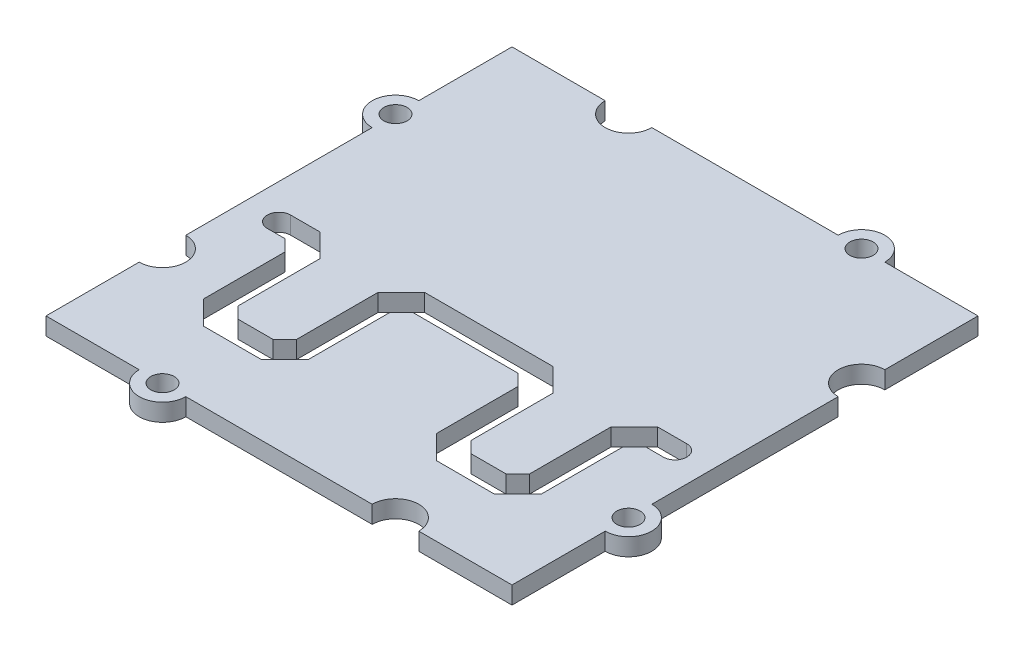
from build123d import *

# Parameters (mm, degrees)
ESQUISSE1_R        = 1
BOSS_EXTRU_1_DEPTH = 1.5


with BuildPart() as part:
    # Esquisse1 → Boss.-Extru.1 (new body)
    with BuildSketch(Plane(origin=(0, 0, 0), x_dir=(1, 0, 0), z_dir=(0, 1, 0))):
        with BuildLine():
            Line((-20, 20), (-12, 20))
            ThreePointArc((-12, 20), (-10, 18), (-8, 20))
            Line((-8, 20), (8, 20))
            ThreePointArc((8, 20), (10, 22), (12, 20))
            Line((12, 20), (20, 20))
            Line((20, 20), (20, 12.001401689))
            ThreePointArc((20, 12.001401689), (17.998598311, 10), (20, 7.998598311))
            Line((20, 7.998598311), (20, -8))
            ThreePointArc((20, -8), (22, -10), (20, -12))
            Line((20, -12), (20, -20))
            Line((20, -20), (12, -20))
            ThreePointArc((12, -20), (10, -18), (8, -20))
            Line((8, -20), (-8, -20))
            ThreePointArc((-8, -20), (-10, -22), (-12, -20))
            Line((-12, -20), (-20, -20))
            Line((-20, -20), (-20, -12))
            ThreePointArc((-20, -12), (-18, -10), (-20, -8))
            Line((-20, -8), (-20, 8))
            ThreePointArc((-20, 8), (-22, 10), (-20, 12))
            Line((-20, 12), (-20, 20))
        make_face()
        with Locations(Location((-10, -20, 0), (0, 0, 270))):  # turned: the seam where the file's is
            Circle(ESQUISSE1_R, mode=Mode.SUBTRACT)
        with Locations(Location((20, -10, 0), (0, 0, 270))):  # turned: the seam where the file's is
            Circle(ESQUISSE1_R, mode=Mode.SUBTRACT)
        with Locations(Location((-20, 10, 0), (0, 0, 270))):  # turned: the seam where the file's is
            Circle(ESQUISSE1_R, mode=Mode.SUBTRACT)
        with Locations(Location((10, 20, 0), (0, 0, 270))):  # turned: the seam where the file's is
            Circle(ESQUISSE1_R, mode=Mode.SUBTRACT)
        with BuildLine():
            Line((-17, -4), (-15.5, -4))
            Line((-15.5, -4), (-14.5, -5))
            Line((-14.5, -5), (-14.5, -12))
            Line((-14.5, -12), (-12.5, -14))
            Line((-12.5, -14), (-7.5, -14))
            Line((-7.5, -14), (-5.5, -12))
            Line((-5.5, -12), (-5.5, -5))
            Line((-5.5, -5), (-4.5, -4))
            Line((-4.5, -4), (4.5, -4))
            Line((4.5, -4), (5.5, -5))
            Line((5.5, -5), (5.5, -12))
            Line((5.5, -12), (7.5, -14))
            Line((7.5, -14), (12.5, -14))
            Line((12.5, -14), (14.5, -12))
            Line((14.5, -12), (14.5, -5))
            Line((14.5, -5), (15.5, -4))
            Line((15.5, -4), (17, -4))
            ThreePointArc((17, -4), (18, -3), (17, -2))
            Line((17, -2), (14.5, -2))
            Line((14.5, -2), (12.5, -4))
            Line((12.5, -4), (12.5, -11))
            Line((12.5, -11), (11.5, -12))
            Line((11.5, -12), (8.5, -12))
            Line((8.5, -12), (7.5, -11))
            Line((7.5, -11), (7.5, -4))
            Line((7.5, -4), (5.5, -2))
            Line((5.5, -2), (-5.5, -2))
            Line((-5.5, -2), (-7.5, -4))
            Line((-7.5, -4), (-7.5, -11))
            Line((-7.5, -11), (-8.5, -12))
            Line((-8.5, -12), (-11.5, -12))
            Line((-11.5, -12), (-12.5, -11))
            Line((-12.5, -11), (-12.5, -4))
            Line((-12.5, -4), (-14.5, -2))
            Line((-14.5, -2), (-17, -2))
            ThreePointArc((-17, -2), (-18, -3), (-17, -4))
        make_face(mode=Mode.SUBTRACT)
    extrude(amount=BOSS_EXTRU_1_DEPTH)


solid = part.part
